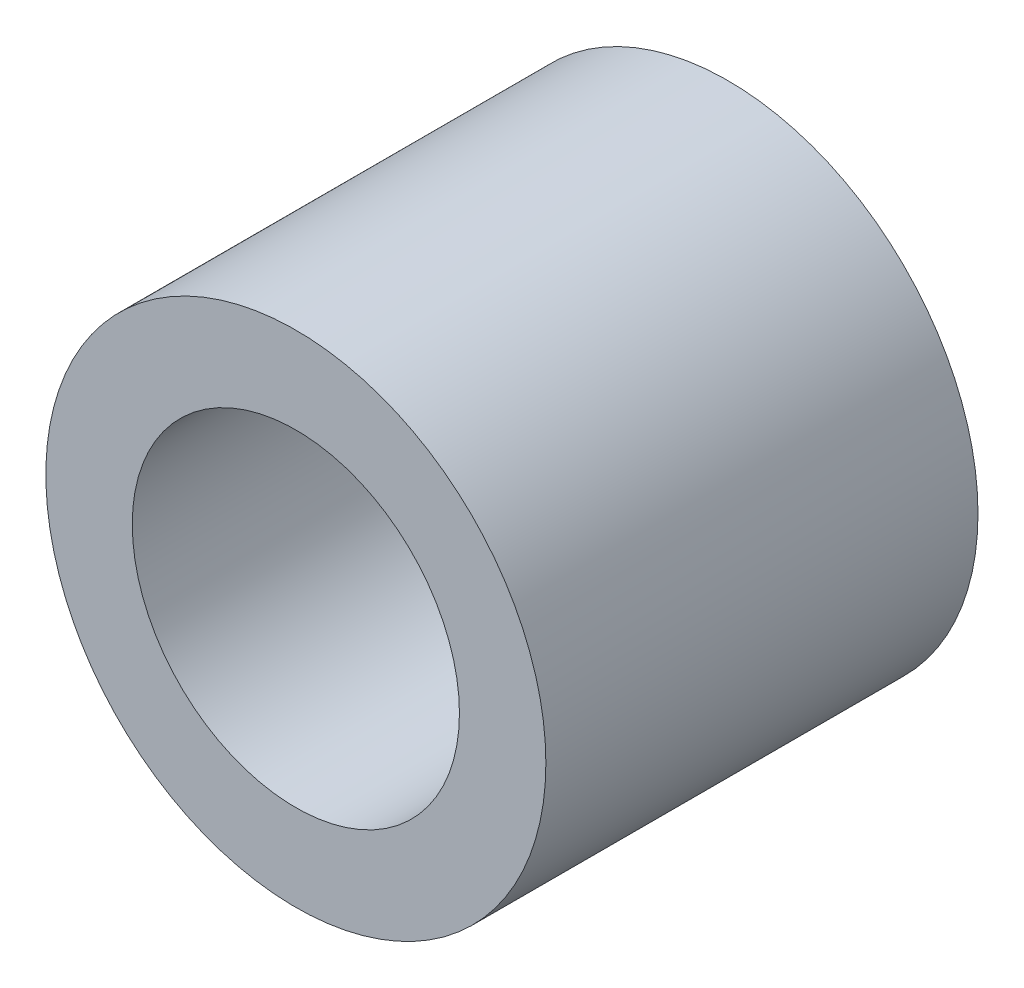
from build123d import *

# Parameters (mm, degrees)
SKETCH1_R            = 4.05
BOSS_EXTRUDE1_DEPTH  = 7
M5_CLEARANCE_HOLE1_D = 5.3


with BuildPart() as part:
    # Sketch1 → Boss-Extrude1 (new body)
    with BuildSketch(Plane.XY):
        Circle(SKETCH1_R)
    extrude(amount=BOSS_EXTRUDE1_DEPTH)

    # M5 Clearance Hole1 (through all)
    with Locations(Plane.XY.offset(7)):
        with Locations((0, 0)):
            Hole(M5_CLEARANCE_HOLE1_D / 2)


solid = part.part
